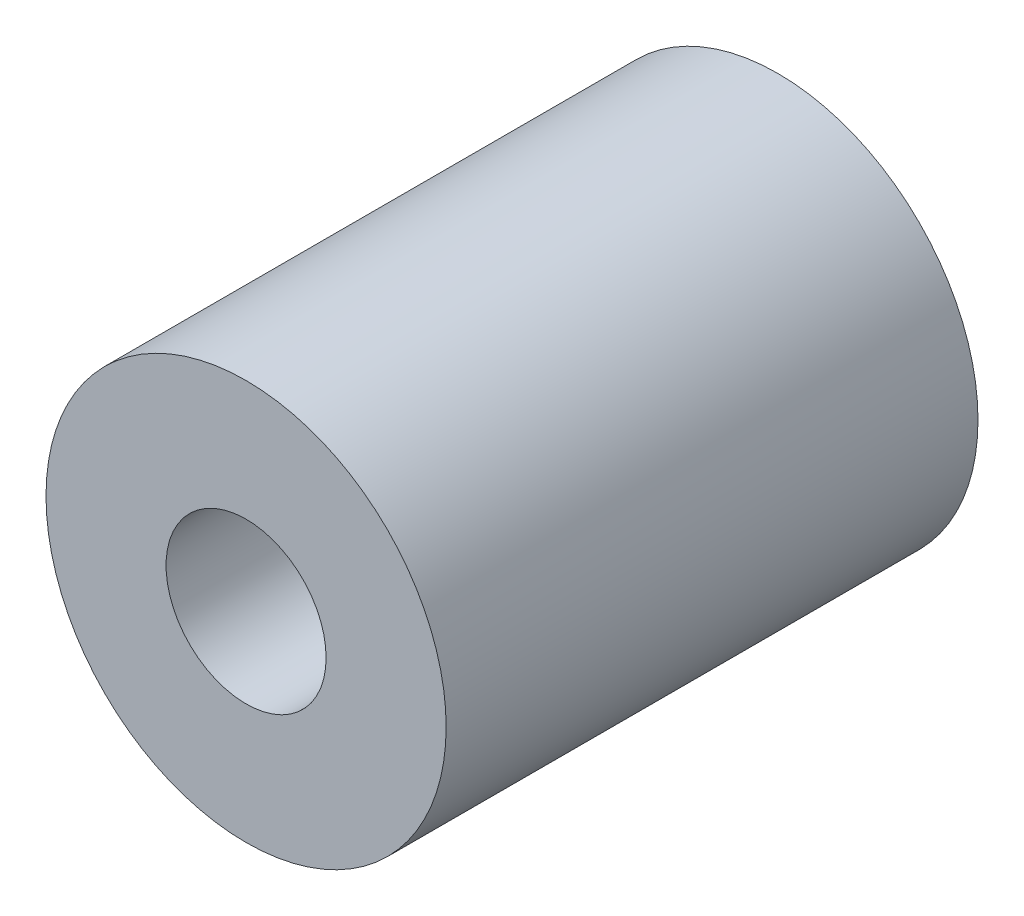
from build123d import *

# Parameters (mm, degrees)
SKETCH2_R            = 2.75
BOSS_EXTRUDE1_DEPTH  = 7.31
M2_CLEARANCE_HOLE1_D = 2.2


with BuildPart() as part:
    # Sketch2 → Boss-Extrude1 (new body)
    with BuildSketch(Plane.XY):
        Circle(SKETCH2_R)
    extrude(amount=BOSS_EXTRUDE1_DEPTH)

    # M2 Clearance Hole1 (through all)
    with Locations(Plane.XY.offset(7.31)):
        with Locations((0, 0)):
            Hole(M2_CLEARANCE_HOLE1_D / 2)


solid = part.part
